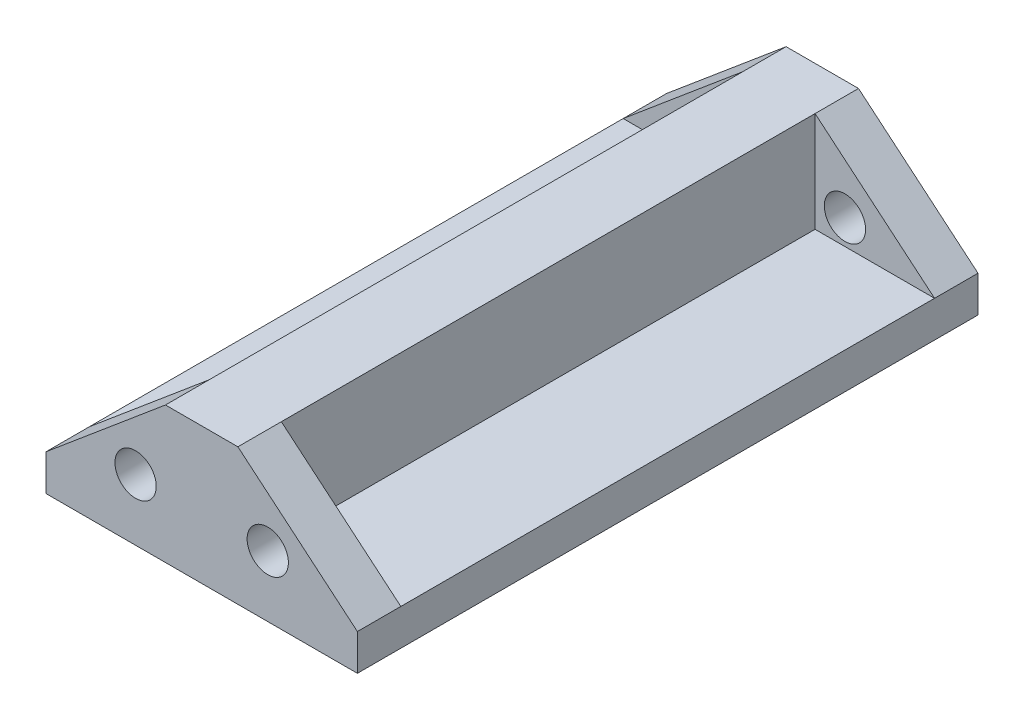
from build123d import *

# Parameters (mm, degrees)
SKETCH1_R           = 2.85
BOSS_EXTRUDE1_DEPTH = 85.7063165
CUT_EXTRUDE1_START  = -6
CUT_EXTRUDE1_DEPTH  = 73.706316
SKETCH3_R           = 2.85
CUT_EXTRUDE2_DEPTH  = 86.7063165


with BuildPart() as part:
    # Sketch1 → Boss-Extrude1 (new body)
    with BuildSketch(Plane.XY):
        Polygon((-21.5, -9.422571957), (21.5, -9.422571957), (21.5, -4.422571957), (5, 9.422571957), (-5, 9.422571957), (-21.5, -4.422571957), align=None)
        with Locations((-9.125, -0.961285979)):
            Circle(SKETCH1_R, mode=Mode.SUBTRACT)
        with Locations((9.125, -0.961285979)):
            Circle(SKETCH1_R, mode=Mode.SUBTRACT)
        with Locations((-9.125, -0.961285979)):
            Circle(SKETCH1_R)
        with Locations((9.125, -0.961285979)):
            Circle(SKETCH1_R)
    extrude(amount=BOSS_EXTRUDE1_DEPTH)

    # Sketch2 → Cut-Extrude1 (cut)
    with BuildSketch(Plane(origin=(0, 0, 0), x_dir=(-1, 0, 0), z_dir=(0, 0, -1)).offset(CUT_EXTRUDE1_START)):
        Polygon((5, 9.422571957), (21.5, -4.422571957), (5, -4.422571957), align=None)
        Polygon((-21.5, -4.422571957), (-5, 9.422571957), (-5, -4.422571957), align=None)
    extrude(amount=-CUT_EXTRUDE1_DEPTH, mode=Mode.SUBTRACT)

    # Sketch3 → Cut-Extrude2 (cut, through all)
    with BuildSketch(Plane(origin=(0, 0, 0), x_dir=(-1, 0, 0), z_dir=(0, 0, -1))):
        with Locations((9.125, -0.961285979)):
            Circle(SKETCH3_R)
        with Locations((-9.125, -0.961285979)):
            Circle(SKETCH3_R)
    extrude(amount=-CUT_EXTRUDE2_DEPTH, mode=Mode.SUBTRACT)


solid = part.part
